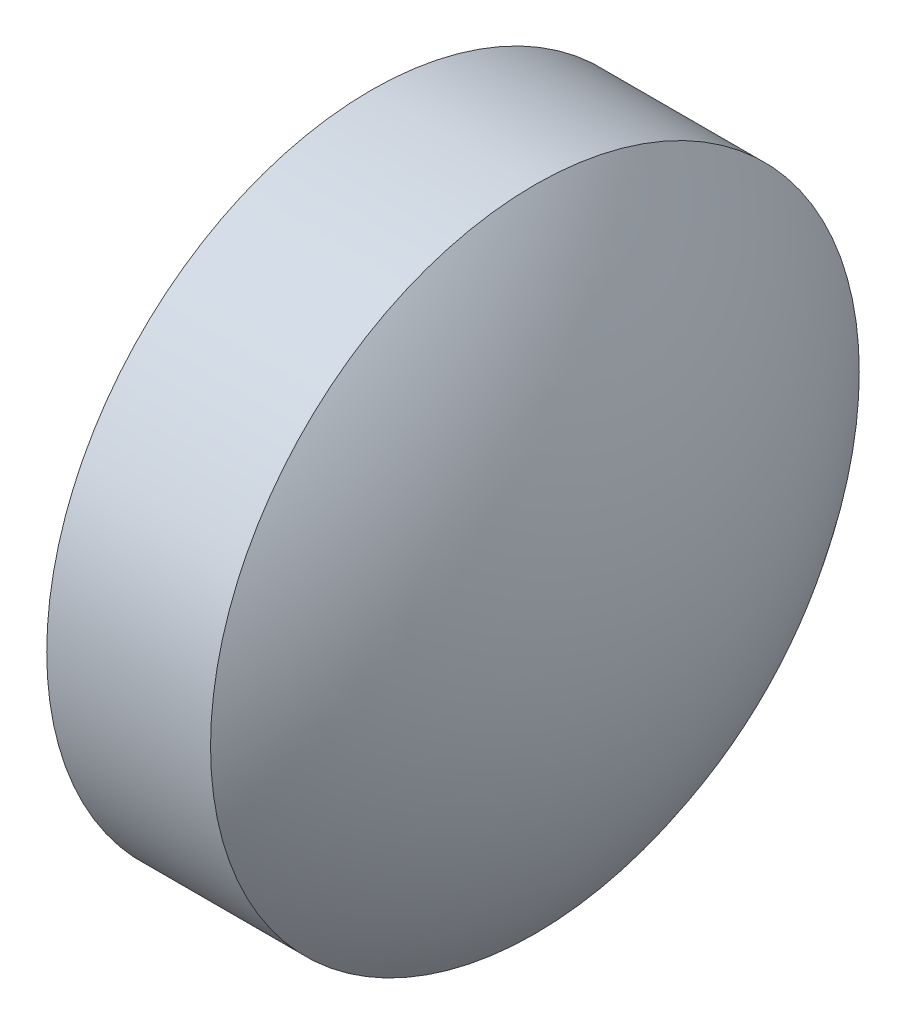
from build123d import *


with BuildPart() as part:
    # 草图1 → 旋转2 (revolve)
    with BuildSketch(Plane.XY):
        with BuildLine():
            Line((506.879867401, -76.133473498), (505.179867401, -76.133473498))
            Line((505.179867401, -76.133473498), (505.179867401, -74.133473498))
            Line((505.179867401, -74.133473498), (506.189867401, -74.133473498))
            ThreePointArc((506.189867401, -74.133473498), (506.702518937, -75.075633718), (506.879867401, -76.133473498))
        make_face()
    revolve(axis=Axis((504.749983265, -76.133473498, 0), (1, 0, 0)))


solid = part.part
